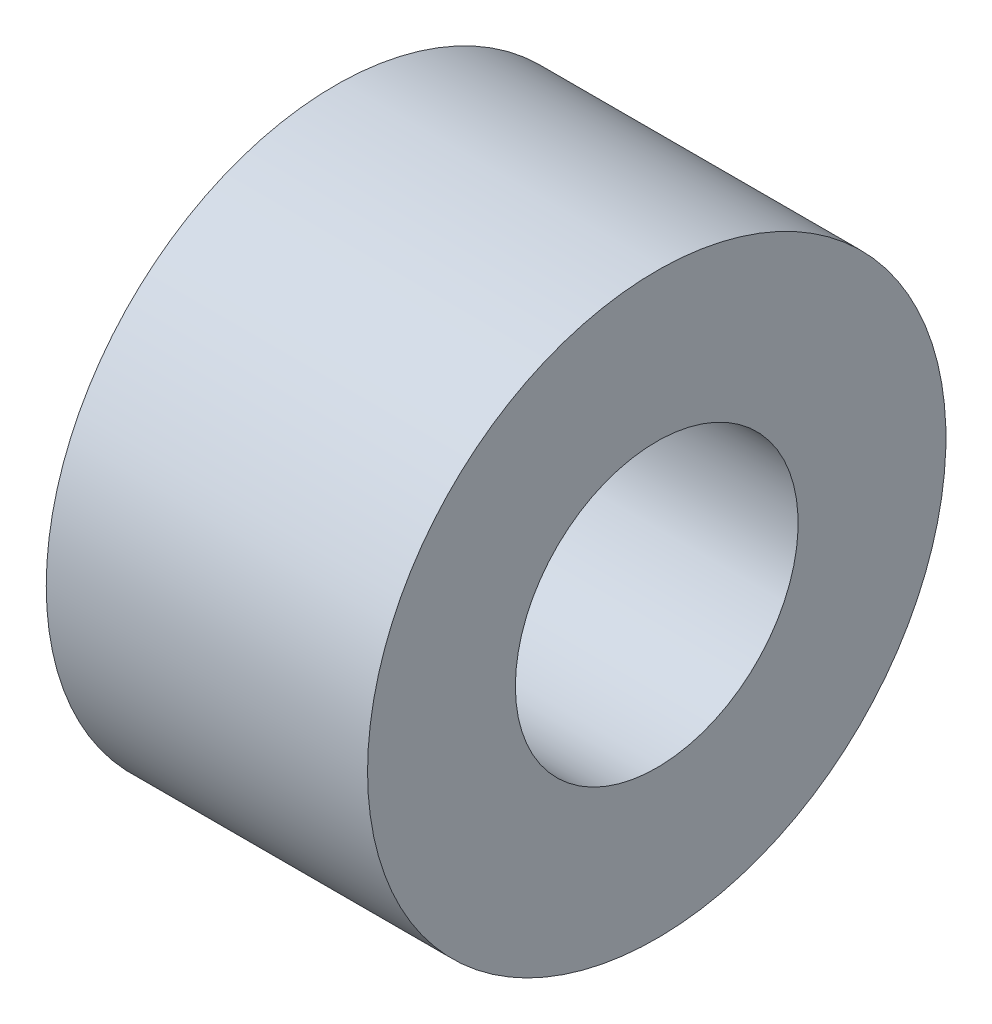
from build123d import *

# Parameters (mm, degrees)
SKETCH1_W = 2.5
SKETCH1_H = 1.15


with BuildPart() as part:
    # Sketch1 → Revolve1 (revolve)
    with BuildSketch(Plane.XY):
        with Locations((1.25, 1.675)):
            Rectangle(SKETCH1_W, SKETCH1_H)
    revolve(axis=Axis((0, 0, 0), (1, 0, 0)))


solid = part.part
